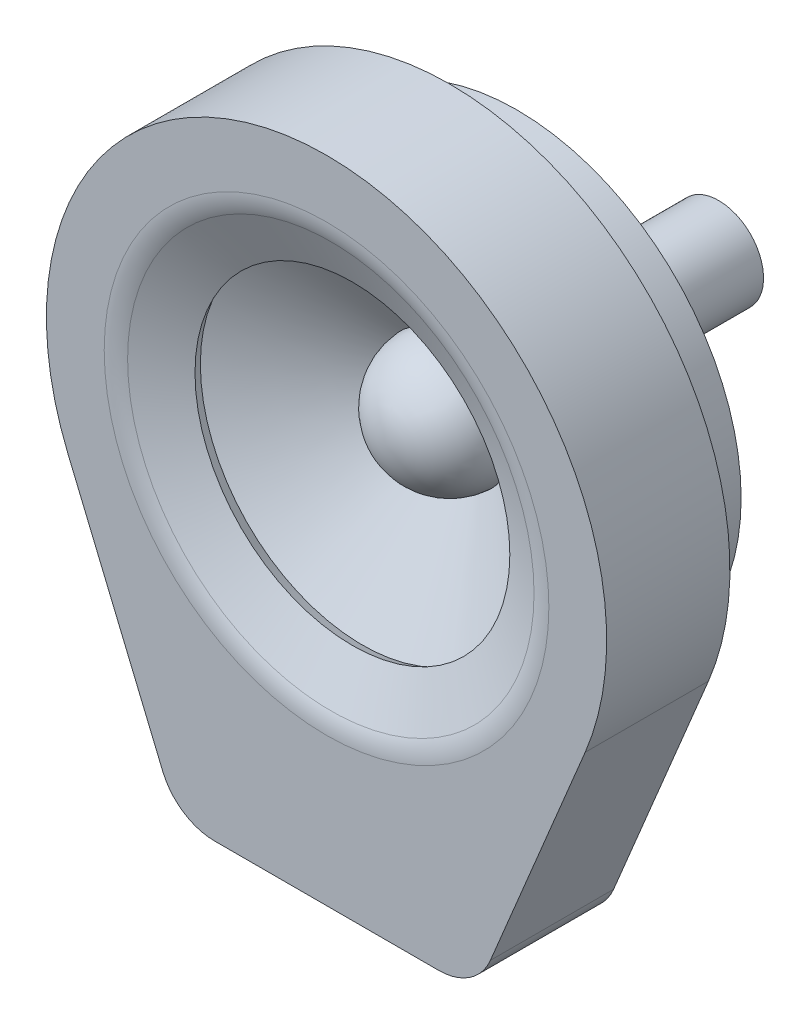
from build123d import *

# Parameters (mm, degrees)
EXTRUDE_THIN1_DEPTH = 5
SKETCH5_R           = 9.973205081
EXTRUDE1_DEPTH      = 0.5
FILLET1_R           = 2


with BuildPart() as part:
    # Sketch1 → Revolve1 (revolve)
    with BuildSketch(Plane(origin=(0, 0, 0), x_dir=(0, 0, -1), z_dir=(1, 0, 0))):
        Polygon((0, 0), (12, 0), (12, 2), (3, 2), (3, 10), (0, 10), align=None)
    revolve(axis=Axis((0, 0, 0), (0, 0, 1)))


with BuildPart() as body_2:
    # Sketch2 → Revolve-Thin2 (revolve)
    with BuildSketch(Plane(origin=(0, 0, 0), x_dir=(0, 0, -1), z_dir=(1, 0, 0))):
        with BuildLine():
            ThreePointArc((-2.778971463, 0), (-1.965029566, 1.965029566), (0, 2.778971463))
            Line((0, 2.778971463), (-3.5917125, 9))
            Line((-3.5917125, 9), (-3.5917125, 11))
            Line((-3.5917125, 11), (-3.6917125, 11))
            Line((-3.6917125, 11), (-3.6917125, 8.973205081))
            Line((-3.6917125, 8.973205081), (-0.170294669, 2.873930482))
            ThreePointArc((-0.170294669, 2.873930482), (-2.095083552, 1.974614291), (-2.878971463, 0))
            Line((-2.878971463, 0), (-2.778971463, 0))
        make_face()
    revolve(axis=Axis((0, 0, 0), (0, 0, 1)))


with BuildPart() as body_3:
    # Sketch4 → Extrude-Thin1 (new body)
    with BuildSketch(Plane.XY):
        with BuildLine():
            Line((7.309705434, -14.961177707), (11.539212944, -4.805888537))
            ThreePointArc((11.539212944, -4.805888537), (0, 12.5), (-11.539212944, -4.805888537))
            Line((-11.539212944, -4.805888537), (-7.309705434, -14.961177707))
            ThreePointArc((-7.309705434, -14.961177707), (-6.388775915, -16.08001734), (-5.001862845, -16.5))
            Line((-5.001862845, -16.5), (5.001862845, -16.5))
            ThreePointArc((5.001862845, -16.5), (6.388775915, -16.08001734), (7.309705434, -14.961177707))
        make_face()
        with BuildLine():
            Line((6.848136916, -14.768942166), (11.077644426, -4.613652995))
            ThreePointArc((11.077644426, -4.613652995), (0, 12), (-11.077644426, -4.613652995))
            Line((-11.077644426, -4.613652995), (-6.848136916, -14.768942166))
            ThreePointArc((-6.848136916, -14.768942166), (-6.111393301, -15.664013872), (-5.001862845, -16))
            Line((-5.001862845, -16), (5.001862845, -16))
            ThreePointArc((5.001862845, -16), (6.111393301, -15.664013872), (6.848136916, -14.768942166))
        make_face(mode=Mode.SUBTRACT)
    extrude(amount=EXTRUDE_THIN1_DEPTH)

    # Sketch5 → Extrude1 (add)
    with BuildSketch(Plane.XY.offset(5)):
        with BuildLine():
            Line((-11.539212944, -4.805888537), (-7.309705434, -14.961177707))
            ThreePointArc((-7.309705434, -14.961177707), (-6.388775915, -16.08001734), (-5.001862845, -16.5))
            Line((-5.001862845, -16.5), (5.001862845, -16.5))
            ThreePointArc((5.001862845, -16.5), (6.388775915, -16.08001734), (7.309705434, -14.961177707))
            Line((7.309705434, -14.961177707), (11.539212944, -4.805888537))
            ThreePointArc((11.539212944, -4.805888537), (0, 12.5), (-11.539212944, -4.805888537))
        make_face()
        Circle(SKETCH5_R, mode=Mode.SUBTRACT)
    extrude(amount=EXTRUDE1_DEPTH)

    # Sketch6 → Revolve-Thin3 (revolve)
    with BuildSketch(Plane(origin=(0, 0, 0), x_dir=(0, 0, -1), z_dir=(1, 0, 0))):
        Polygon((-5.5, 9.973205081), (-5.5, 9.473205081), (-4.345447499, 7.024699681), (-3.893202995, 7.237948147), (-5, 9.585176568), (-5, 9.973205081), align=None)
    revolve(axis=Axis((0, 0, 0), (0, 0, 1)))

    # Fillet1
    fillet1_edges = [body_3.edges().sort_by_distance(p)[0] for p in [
        (0, -9.473205081, 5.5),
    ]]
    fillet(fillet1_edges, radius=FILLET1_R)


solid = Compound([part.part, body_2.part, body_3.part])
